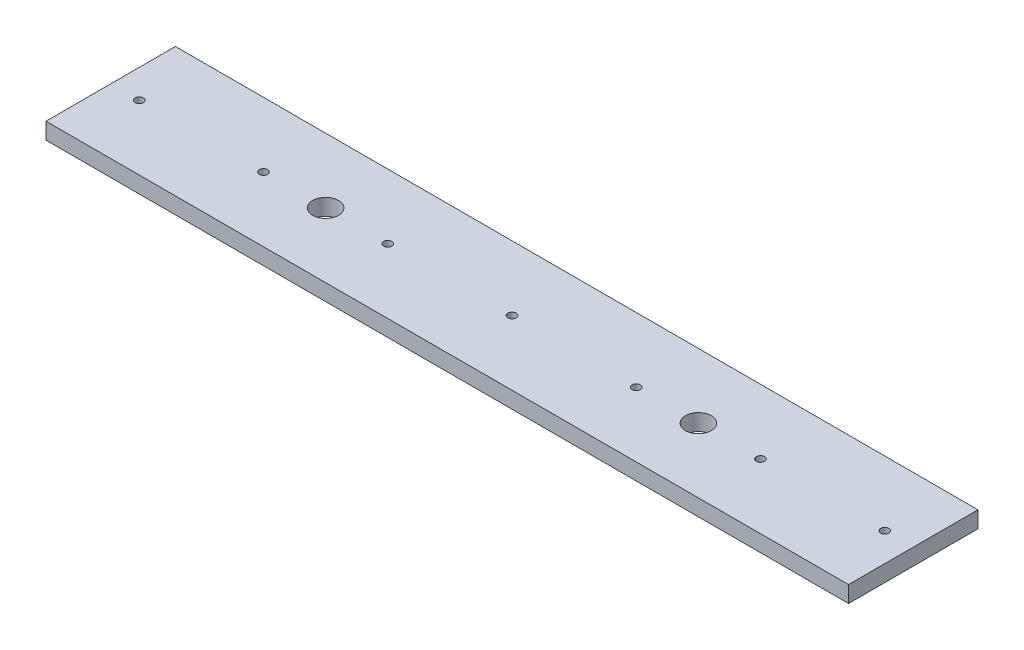
from build123d import *

# Parameters (mm, degrees)
CROQUIS1_W              = 310
CROQUIS1_H              = 50
SALIENTE_EXTRUIR1_DEPTH = 6.35
CROQUIS2_R              = 1.5875
CROQUIS2_R_2            = 5
CORTAR_EXTRUIR3_DEPTH   = 7.35


with BuildPart() as part:
    # Croquis1 → Saliente-Extruir1 (new body)
    with BuildSketch(Plane(origin=(0, 0, 0), x_dir=(1, 0, 0), z_dir=(0, 1, 0))):
        Rectangle(CROQUIS1_W, CROQUIS1_H)
    extrude(amount=SALIENTE_EXTRUIR1_DEPTH)

    # Croquis2 → Cortar-Extruir3 (cut, through all)
    with BuildSketch(Plane(origin=(0, 6.35, 0), x_dir=(1, 0, 0), z_dir=(0, 1, 0))):
        Circle(CROQUIS2_R)
        with Locations((-144, 0)):
            Circle(CROQUIS2_R)
        with Locations((144, 0)):
            Circle(CROQUIS2_R)
        with Locations((48, 0)):
            Circle(CROQUIS2_R)
        with Locations((96, 0)):
            Circle(CROQUIS2_R)
        with Locations((-48, 0)):
            Circle(CROQUIS2_R)
        with Locations((-96, 0)):
            Circle(CROQUIS2_R)
        with Locations((-72, 0)):
            Circle(CROQUIS2_R_2)
        with Locations((72, 0)):
            Circle(CROQUIS2_R_2)
    extrude(amount=-CORTAR_EXTRUIR3_DEPTH, mode=Mode.SUBTRACT)


solid = part.part
